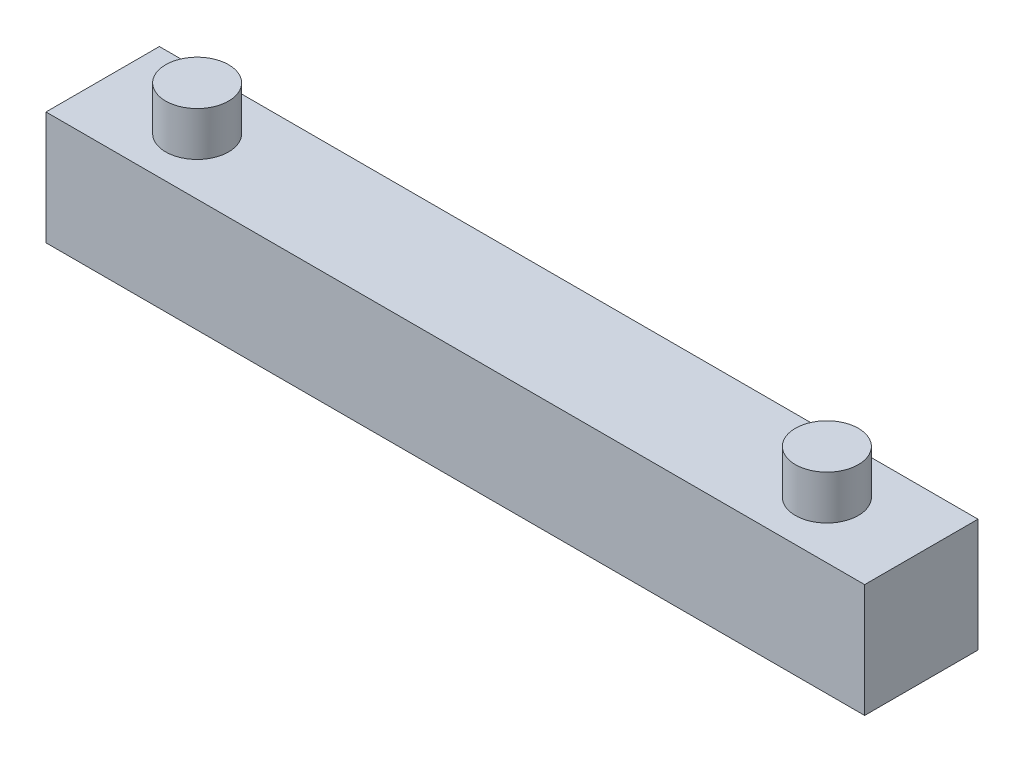
from build123d import *

# Parameters (mm, degrees)
SKETCH1_W           = 65
SKETCH1_H           = 9
BOSS_EXTRUDE1_DEPTH = 9
SKETCH2_R           = 2.5
BOSS_EXTRUDE2_DEPTH = 3.5


with BuildPart() as part:
    # Sketch1 → Boss-Extrude1 (new body)
    with BuildSketch(Plane(origin=(0, 0, 0), x_dir=(1, 0, 0), z_dir=(0, 1, 0))):
        with Locations((32.5, 4.5)):
            Rectangle(SKETCH1_W, SKETCH1_H)
    extrude(amount=BOSS_EXTRUDE1_DEPTH)

    # Sketch2 → Boss-Extrude2 (add)
    with BuildSketch(Plane(origin=(0, 9, 0), x_dir=(1, 0, 0), z_dir=(0, 1, 0))):
        with Locations(Location((7.5, 4.5, 0), (0, 0, 90))):  # turned: the seam where the file's is
            Circle(SKETCH2_R)
        with Locations(Location((57.5, 4.5, 0), (0, 0, 90))):  # turned: the seam where the file's is
            Circle(SKETCH2_R)
    extrude(amount=BOSS_EXTRUDE2_DEPTH)


solid = part.part
